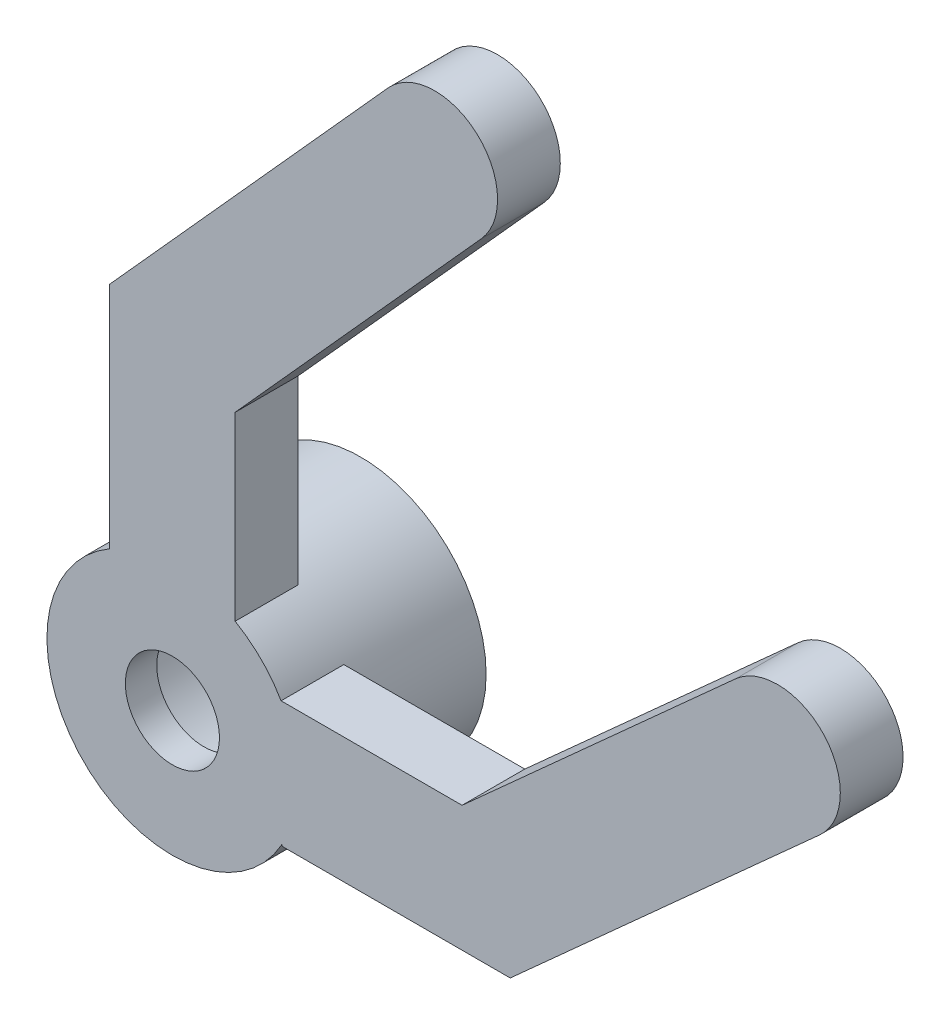
from build123d import *

# Parameters (mm, degrees)
ESQUISSE4_R        = 4
ESQUISSE4_R_2      = 3
BOSS_EXTRU_1_DEPTH = 6
ESQUISSE6_R        = 3
ESQUISSE6_R_2      = 1.5
BOSS_EXTRU_2_DEPTH = 1
BOSS_EXTRU_3_DEPTH = 2


with BuildPart() as part:
    # Esquisse4 → Boss.-Extru.1 (new body)
    with BuildSketch(Plane.XY):
        Circle(ESQUISSE4_R)
        Circle(ESQUISSE4_R_2, mode=Mode.SUBTRACT)
    extrude(amount=BOSS_EXTRU_1_DEPTH)

    # Esquisse6 → Boss.-Extru.2 (add)
    with BuildSketch(Plane.XY.offset(6)):
        Circle(ESQUISSE6_R)
        Circle(ESQUISSE6_R_2, mode=Mode.SUBTRACT)
    extrude(amount=-BOSS_EXTRU_2_DEPTH)

    # Esquisse7 → Boss.-Extru.3 (add)
    with BuildSketch(Plane.XY.offset(6)):
        with BuildLine():
            ThreePointArc((3.464101615, 2), (3.863703305, 1.03527618), (4, 0))
            ThreePointArc((4, 0), (3.870082468, -1.011168479), (3.488769153, -1.956652702))
            Line((3.488769153, -1.956652702), (3.505079435, -2))
            Line((3.505079435, -2), (10.76772807, -2))
            Line((10.76772807, -2), (20.627571531, 6.877842929))
            ThreePointArc((20.627571531, 6.877842929), (20.775599969, 9.702393792), (17.951049106, 9.85042223))
            Line((17.951049106, 9.85042223), (9.23227193, 2))
            Line((9.23227193, 2), (3.464101615, 2))
        make_face()
        with BuildLine():
            ThreePointArc((0, 4), (1.03527618, 3.863703305), (2, 3.464101615))
            Line((2, 3.464101615), (2, 9.23227193))
            Line((2, 9.23227193), (9.85042223, 17.951049106))
            ThreePointArc((9.85042223, 17.951049106), (9.702393792, 20.775599969), (6.877842929, 20.627571531))
            Line((6.877842929, 20.627571531), (-2, 10.76772807))
            Line((-2, 10.76772807), (-2, 3.464101615))
            ThreePointArc((-2, 3.464101615), (-1.03527618, 3.863703305), (0, 4))
        make_face()
    extrude(amount=-BOSS_EXTRU_3_DEPTH)


solid = part.part
